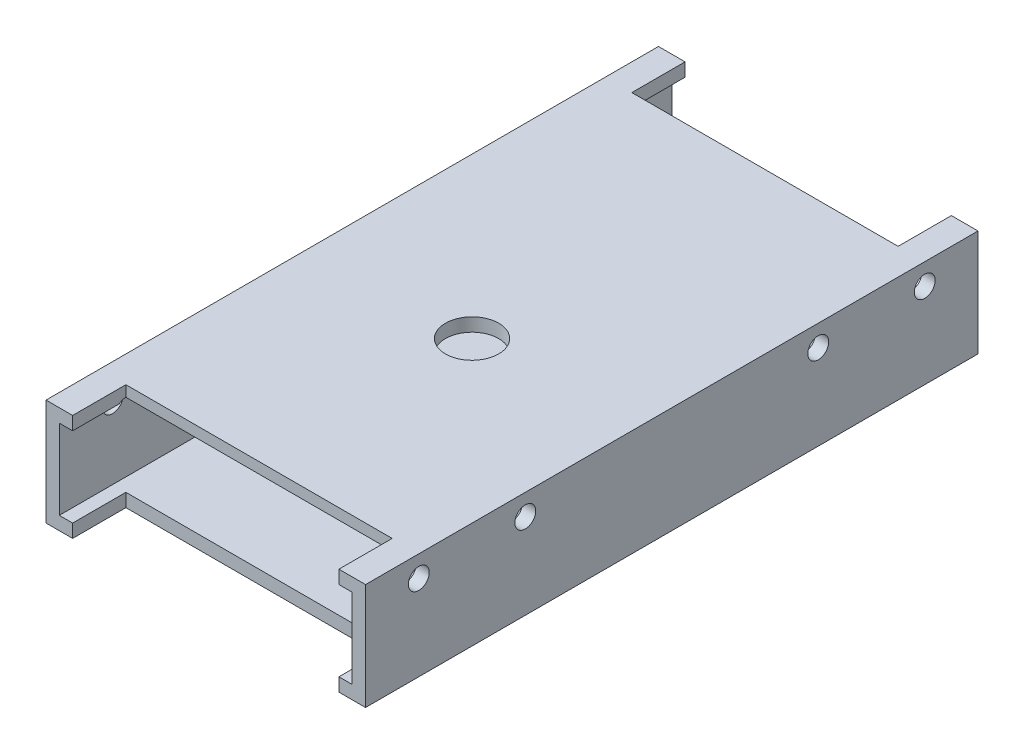
from build123d import *

# Parameters (mm, degrees)
SKETCH1_W               = 76.2
SKETCH1_H               = 25.4
SKETCH1_W_2             = 69.85
SKETCH1_H_2             = 19.05
EXTRUDE_THIN1_DEPTH     = 73.025
SKETCH2_W               = 63.5
SKETCH2_H               = 12.7
CUT_EXTRUDE1_DEPTH      = 26.4
SKETCH3_R               = 2.4892
CUT_EXTRUDE2_DEPTH      = 1
CUT_EXTRUDE2_DEPTH_BACK = 77.2
SKETCH4_R               = 6.35
CUT_EXTRUDE3_DEPTH      = 26.4


with BuildPart() as part:
    # Sketch1 → Extrude-Thin1 (new body, symmetric)
    with BuildSketch(Plane.XY):
        Rectangle(SKETCH1_W, SKETCH1_H)
        Rectangle(SKETCH1_W_2, SKETCH1_H_2, mode=Mode.SUBTRACT)
    extrude(amount=EXTRUDE_THIN1_DEPTH, both=True)

    # Sketch2 → Cut-Extrude1 (cut, through all)
    with BuildSketch(Plane.XZ.offset(12.7)):
        with Locations((0, -66.675)):
            Rectangle(SKETCH2_W, SKETCH2_H)
        with Locations((0, 66.675)):
            Rectangle(SKETCH2_W, SKETCH2_H)
    extrude(amount=-CUT_EXTRUDE1_DEPTH, mode=Mode.SUBTRACT)

    # Sketch3 → Cut-Extrude2 (cut, two sides)
    with BuildSketch(Plane(origin=(38.1, 0, 0), x_dir=(0, 0, -1), z_dir=(1, 0, 0))) as cut_extrude2_sk:
        with Locations((60.325, 7.62)):
            Circle(SKETCH3_R)
        with Locations((34.925, 7.62)):
            Circle(SKETCH3_R)
        with Locations((-34.925, 7.62)):
            Circle(SKETCH3_R)
        with Locations((-60.325, 7.62)):
            Circle(SKETCH3_R)
    extrude(amount=CUT_EXTRUDE2_DEPTH, mode=Mode.SUBTRACT)
    extrude(cut_extrude2_sk.sketch, amount=-CUT_EXTRUDE2_DEPTH_BACK, mode=Mode.SUBTRACT)

    # Sketch4 → Cut-Extrude3 (cut, through all)
    with BuildSketch(Plane.XZ.offset(12.7)):
        with Locations((0, 9.525)):
            Circle(SKETCH4_R)
    extrude(amount=-CUT_EXTRUDE3_DEPTH, mode=Mode.SUBTRACT)


solid = part.part
